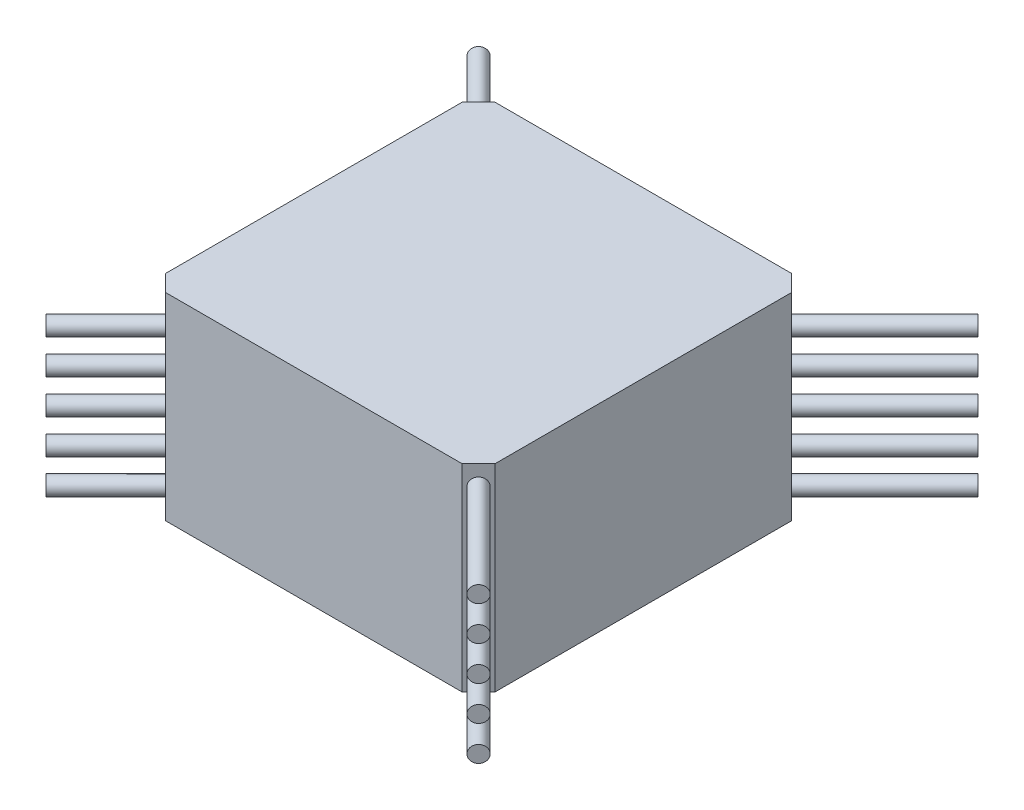
from build123d import *

# Parameters (mm, degrees)
BOSS_EXTRUDE1_DEPTH        = 30
SKETCH2_R                  = 1.25
BOSS_EXTRUDE2_DEPTH        = 20
BOSS_EXTRUDE2_DEPTH_BACK   = 80
BOSS_EXTRUDE2_2_DEPTH      = 20
BOSS_EXTRUDE2_2_DEPTH_BACK = 80
BOSS_EXTRUDE2_3_DEPTH      = 20
BOSS_EXTRUDE2_3_DEPTH_BACK = 80
BOSS_EXTRUDE2_4_DEPTH      = 20
BOSS_EXTRUDE2_4_DEPTH_BACK = 80
BOSS_EXTRUDE2_5_DEPTH      = 20
BOSS_EXTRUDE2_5_DEPTH_BACK = 80
SKETCH3_R                  = 1.25
BOSS_EXTRUDE3_DEPTH        = 20
BOSS_EXTRUDE3_DEPTH_BACK   = 80
BOSS_EXTRUDE3_2_DEPTH      = 20
BOSS_EXTRUDE3_2_DEPTH_BACK = 80
BOSS_EXTRUDE3_3_DEPTH      = 20
BOSS_EXTRUDE3_3_DEPTH_BACK = 80
BOSS_EXTRUDE3_4_DEPTH      = 20
BOSS_EXTRUDE3_4_DEPTH_BACK = 80
BOSS_EXTRUDE3_5_DEPTH      = 20
BOSS_EXTRUDE3_5_DEPTH_BACK = 80


with BuildPart() as part:
    # Sketch1 → Boss-Extrude1 (new body)
    with BuildSketch(Plane(origin=(0, 0, 0), x_dir=(1, 0, 0), z_dir=(0, 1, 0))):
        Polygon((-22.5, -25), (22.5, -25), (25, -22.5), (25, 22.5), (22.5, 25), (-22.5, 25), (-25, 22.5), (-25, -22.5), align=None)
    extrude(amount=BOSS_EXTRUDE1_DEPTH)


with BuildPart() as body_2:
    # Sketch2 → Boss-Extrude2 (new body, two sides)
    with BuildSketch(Plane(origin=(23.75, 0, 23.75), x_dir=(0.707106781, 0, -0.707106781), z_dir=(0.707106781, 0, 0.707106781))) as boss_extrude2_sk:
        with Locations((0, 27)):
            Circle(SKETCH2_R)
    extrude(amount=BOSS_EXTRUDE2_DEPTH)
    extrude(boss_extrude2_sk.sketch, amount=-BOSS_EXTRUDE2_DEPTH_BACK)


with BuildPart() as body_3:
    # Sketch2 → Boss-Extrude2 2 (new body, two sides)
    with BuildSketch(Plane(origin=(23.75, 0, 23.75), x_dir=(0.707106781, 0, -0.707106781), z_dir=(0.707106781, 0, 0.707106781))) as boss_extrude2_2_sk:
        with Locations((0, 21.75)):
            Circle(SKETCH2_R)
    extrude(amount=BOSS_EXTRUDE2_2_DEPTH)
    extrude(boss_extrude2_2_sk.sketch, amount=-BOSS_EXTRUDE2_2_DEPTH_BACK)


with BuildPart() as body_4:
    # Sketch2 → Boss-Extrude2 3 (new body, two sides)
    with BuildSketch(Plane(origin=(23.75, 0, 23.75), x_dir=(0.707106781, 0, -0.707106781), z_dir=(0.707106781, 0, 0.707106781))) as boss_extrude2_3_sk:
        with Locations((0, 16.5)):
            Circle(SKETCH2_R)
    extrude(amount=BOSS_EXTRUDE2_3_DEPTH)
    extrude(boss_extrude2_3_sk.sketch, amount=-BOSS_EXTRUDE2_3_DEPTH_BACK)


with BuildPart() as body_5:
    # Sketch2 → Boss-Extrude2 4 (new body, two sides)
    with BuildSketch(Plane(origin=(23.75, 0, 23.75), x_dir=(0.707106781, 0, -0.707106781), z_dir=(0.707106781, 0, 0.707106781))) as boss_extrude2_4_sk:
        with Locations((0, 11.25)):
            Circle(SKETCH2_R)
    extrude(amount=BOSS_EXTRUDE2_4_DEPTH)
    extrude(boss_extrude2_4_sk.sketch, amount=-BOSS_EXTRUDE2_4_DEPTH_BACK)


with BuildPart() as body_6:
    # Sketch2 → Boss-Extrude2 5 (new body, two sides)
    with BuildSketch(Plane(origin=(23.75, 0, 23.75), x_dir=(0.707106781, 0, -0.707106781), z_dir=(0.707106781, 0, 0.707106781))) as boss_extrude2_5_sk:
        with Locations((0, 6)):
            Circle(SKETCH2_R)
    extrude(amount=BOSS_EXTRUDE2_5_DEPTH)
    extrude(boss_extrude2_5_sk.sketch, amount=-BOSS_EXTRUDE2_5_DEPTH_BACK)


with BuildPart() as body_7:
    # Sketch3 → Boss-Extrude3 (new body, two sides)
    with BuildSketch(Plane(origin=(23.75, 0, -23.75), x_dir=(-0.707106781, 0, -0.707106781), z_dir=(0.707106781, 0, -0.707106781))) as boss_extrude3_sk:
        with Locations((0, 24.4)):
            Circle(SKETCH3_R)
    extrude(amount=BOSS_EXTRUDE3_DEPTH)
    extrude(boss_extrude3_sk.sketch, amount=-BOSS_EXTRUDE3_DEPTH_BACK)


with BuildPart() as body_8:
    # Sketch3 → Boss-Extrude3 2 (new body, two sides)
    with BuildSketch(Plane(origin=(23.75, 0, -23.75), x_dir=(-0.707106781, 0, -0.707106781), z_dir=(0.707106781, 0, -0.707106781))) as boss_extrude3_2_sk:
        with Locations((0, 19.15)):
            Circle(SKETCH3_R)
    extrude(amount=BOSS_EXTRUDE3_2_DEPTH)
    extrude(boss_extrude3_2_sk.sketch, amount=-BOSS_EXTRUDE3_2_DEPTH_BACK)


with BuildPart() as body_9:
    # Sketch3 → Boss-Extrude3 3 (new body, two sides)
    with BuildSketch(Plane(origin=(23.75, 0, -23.75), x_dir=(-0.707106781, 0, -0.707106781), z_dir=(0.707106781, 0, -0.707106781))) as boss_extrude3_3_sk:
        with Locations((0, 13.9)):
            Circle(SKETCH3_R)
    extrude(amount=BOSS_EXTRUDE3_3_DEPTH)
    extrude(boss_extrude3_3_sk.sketch, amount=-BOSS_EXTRUDE3_3_DEPTH_BACK)


with BuildPart() as body_10:
    # Sketch3 → Boss-Extrude3 4 (new body, two sides)
    with BuildSketch(Plane(origin=(23.75, 0, -23.75), x_dir=(-0.707106781, 0, -0.707106781), z_dir=(0.707106781, 0, -0.707106781))) as boss_extrude3_4_sk:
        with Locations((0, 8.65)):
            Circle(SKETCH3_R)
    extrude(amount=BOSS_EXTRUDE3_4_DEPTH)
    extrude(boss_extrude3_4_sk.sketch, amount=-BOSS_EXTRUDE3_4_DEPTH_BACK)


with BuildPart() as body_11:
    # Sketch3 → Boss-Extrude3 5 (new body, two sides)
    with BuildSketch(Plane(origin=(23.75, 0, -23.75), x_dir=(-0.707106781, 0, -0.707106781), z_dir=(0.707106781, 0, -0.707106781))) as boss_extrude3_5_sk:
        with Locations((0, 3.4)):
            Circle(SKETCH3_R)
    extrude(amount=BOSS_EXTRUDE3_5_DEPTH)
    extrude(boss_extrude3_5_sk.sketch, amount=-BOSS_EXTRUDE3_5_DEPTH_BACK)


solid = Compound([part.part, body_2.part, body_3.part, body_4.part, body_5.part, body_6.part, body_7.part, body_8.part, body_9.part, body_10.part, body_11.part])
